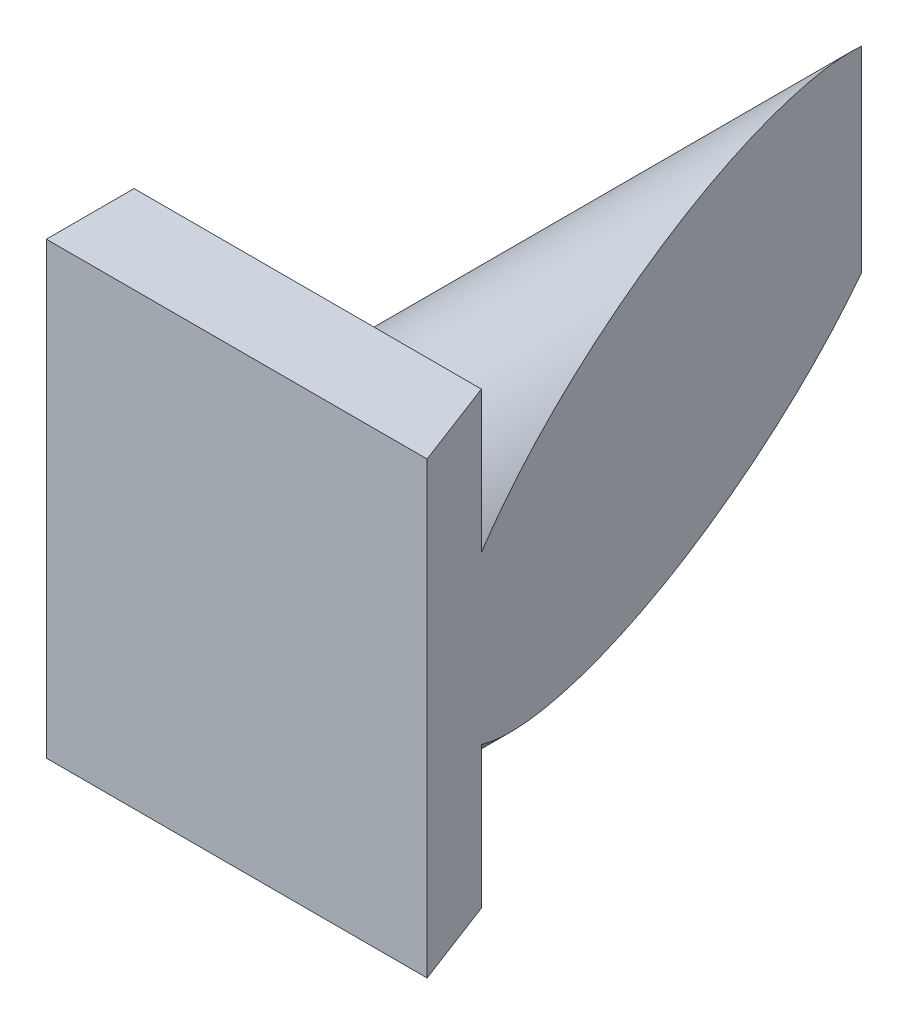
from build123d import *

# Parameters (mm, degrees)
SKETCH1_R               = 16.892448346
BOSS_EXTRUDE1_DEPTH     = 70
SKETCH2_W               = 51.249127752
SKETCH2_H               = 51.249127751
BOSS_EXTRUDE2_DEPTH     = 10
CUT_EXTRUDE1_DEPTH      = 20.696737014
CUT_EXTRUDE1_DEPTH_BACK = 32.552390737


with BuildPart() as part:
    # Sketch1 → Boss-Extrude1 (new body)
    with BuildSketch(Plane.XY):
        with Locations((-8.123318292, -5.927826862)):
            Circle(SKETCH1_R)
    extrude(amount=BOSS_EXTRUDE1_DEPTH)

    # Sketch2 → Boss-Extrude2 (add)
    with BuildSketch(Plane.XY.offset(70)):
        with Locations((-8.123318292, -5.927826862)):
            Rectangle(SKETCH2_W, SKETCH2_H)
    extrude(amount=BOSS_EXTRUDE2_DEPTH)

    # Sketch3 → Cut-Extrude1 (cut, two sides)
    with BuildSketch(Plane(origin=(0, 0, 0), x_dir=(1, 0, 0), z_dir=(0, 1, 0))) as cut_extrude1_sk:
        Polygon((-25.712291526, 12.946943155), (18.961130043, -104.420154992), (40.320792226, 8.610459854), align=None)
    extrude(amount=CUT_EXTRUDE1_DEPTH, mode=Mode.SUBTRACT)
    extrude(cut_extrude1_sk.sketch, amount=-CUT_EXTRUDE1_DEPTH_BACK, mode=Mode.SUBTRACT)


solid = part.part
